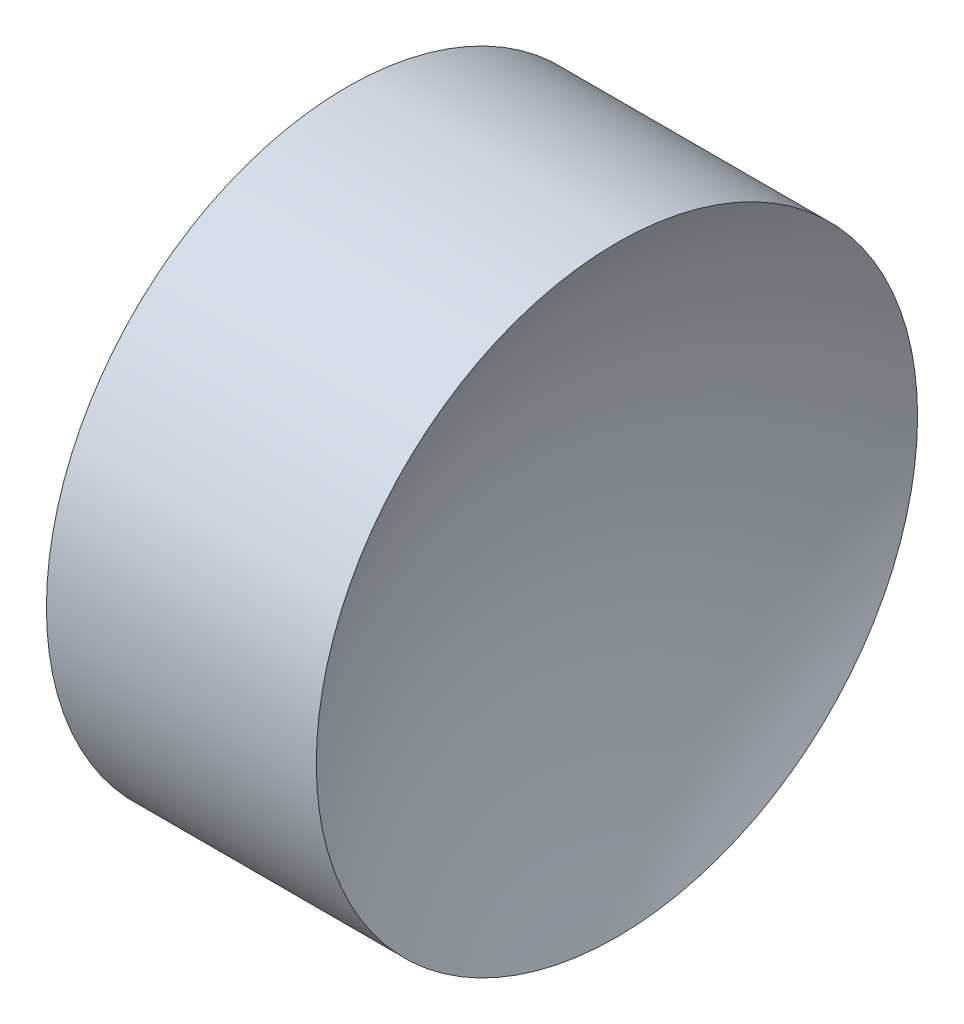
from build123d import *


with BuildPart() as part:
    # 草图1 → 旋转1 (revolve)
    with BuildSketch(Plane.XY, mode=Mode.PRIVATE) as revolve_1_sk:
        with BuildLine():
            Line((46.795221984, 26.089041149), (49.295221984, 26.089041149))
            ThreePointArc((49.295221984, 26.089041149), (49.701404599, 29.363290643), (50.895327917, 32.439041149))
            Line((50.895327917, 32.439041149), (48.045221984, 32.439041149))
            Line((48.045221984, 32.439041149), (45.195116052, 32.439041149))
            ThreePointArc((45.195116052, 32.439041149), (46.38903937, 29.363290643), (46.795221984, 26.089041149))
        make_face()
    revolve(revolve_1_sk.sketch.rotate(Axis((42.449861114, 26.089041149, 0), (1, 0, 0)), 90), axis=Axis((42.449861114, 26.089041149, 0), (1, 0, 0)))  # turned: the seam where the file's is


solid = part.part
